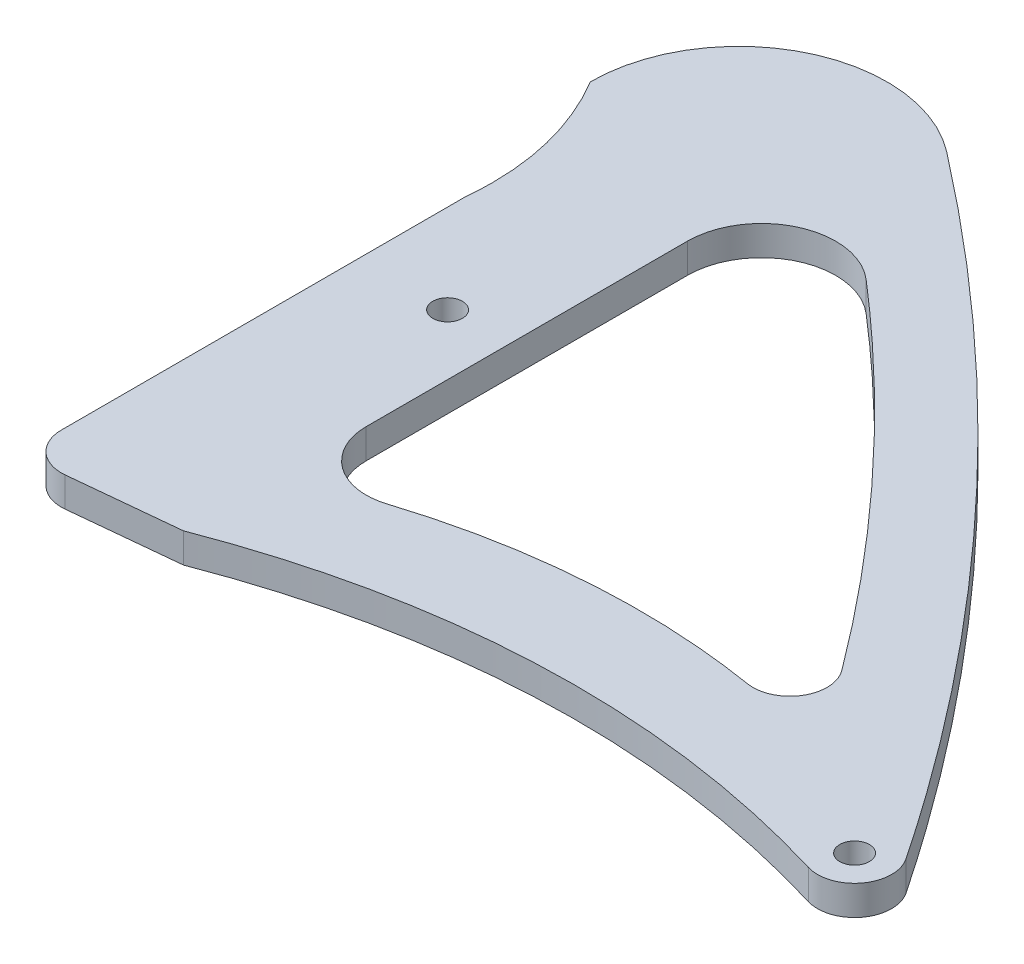
from build123d import *

# Parameters (mm, degrees)
BOSS_EXTRUDE1_DEPTH = 2
SKETCH2_R           = 1
CUT_EXTRUDE1_DEPTH  = 3.0000001


with BuildPart() as part:
    # Sketch1 → Boss-Extrude1 (new body)
    with BuildSketch(Plane(origin=(0, 0, 0), x_dir=(1, 0, 0), z_dir=(0, 1, 0))):
        with BuildLine():
            Line((5.248759298, 0.27487593), (12.5, 1))
            add(Edge.make_bspline(
                [(12.5, 1), (25.716292058, 6.056775104), (39.5099436, 6.545604881), (53.220608515, 2.413649078)],
                knots=[0, 0, 0, 0, 0.858701094, 0.858701094, 0.858701094, 0.858701094], degree=3))
            ThreePointArc((53.220608515, 2.413649078), (55.952811517, 3.321860873), (56.017920205, 6.200322748))
            add(Edge.make_bspline(
                [(16.11119686, 48.85407535), (22.252071457, 44.112915248), (36.940561271, 31.197181318), (49.405904782, 16.053895714), (56.017920205, 6.200322748)],
                knots=[0.227142679, 0.227142679, 0.227142679, 0.227142679, 0.499193547, 0.914214996, 0.914214996, 0.914214996, 0.914214996], degree=3))
            ThreePointArc((16.11119686, 48.85407535), (5.590463097, 49.913991867), (0, 40.938693304))
            add(Edge.make_bspline(
                [(0, 40.938693304), (3.065585296, 35.767628216), (2.5, 30)],
                knots=[0, 0, 0, 1, 1, 1], degree=2))
            Line((2.5, 30), (2.5, 2.762468905))
            ThreePointArc((2.5, 2.762468905), (3.322486698, 0.908837571), (5.248759298, 0.27487593))
        make_face()
    extrude(amount=BOSS_EXTRUDE1_DEPTH)

    # Sketch2 → Cut-Extrude1 (cut, through all)
    with BuildSketch(Plane(origin=(0, 2, 0), x_dir=(1, 0, 0), z_dir=(0, 1, 0))):
        with Locations((53.941981842, 4.807311653)):
            Circle(SKETCH2_R)
        with Locations((8.5, 22.807311653)):
            Circle(SKETCH2_R)
        with BuildLine():
            Line((12.575662954, 34.90249481), (12.575662954, 13.24232221))
            ThreePointArc((12.575662954, 13.24232221), (14.214859141, 10.01329676), (17.788965632, 9.430774412))
            add(Edge.make_bspline(
                [(40.437472292, 11.085030457), (37.44717133, 11.574532132), (29.837808842, 12.110288208), (22.250510571, 10.850986019), (17.788965632, 9.430774412)],
                knots=[0.180465319, 0.180465319, 0.180465319, 0.180465319, 0.4409169, 0.841911756, 0.841911756, 0.841911756, 0.841911756], degree=3))
            ThreePointArc((40.437472292, 11.085030457), (42.977221324, 12.252961632), (42.846470999, 15.045324919))
            add(Edge.make_bspline(
                [(20.840843033, 38.689129074), (25.058258326, 35.052490455), (32.827221728, 27.546668383), (39.711612857, 19.255139389), (42.846470999, 15.045324919)],
                knots=[0.21322067, 0.21322067, 0.21322067, 0.21322067, 0.550339586, 0.867457281, 0.867457281, 0.867457281, 0.867457281], degree=3))
            ThreePointArc((20.840843033, 38.689129074), (15.493104479, 39.448146601), (12.575662954, 34.90249481))
        make_face()
    extrude(amount=-CUT_EXTRUDE1_DEPTH, mode=Mode.SUBTRACT)


solid = part.part
